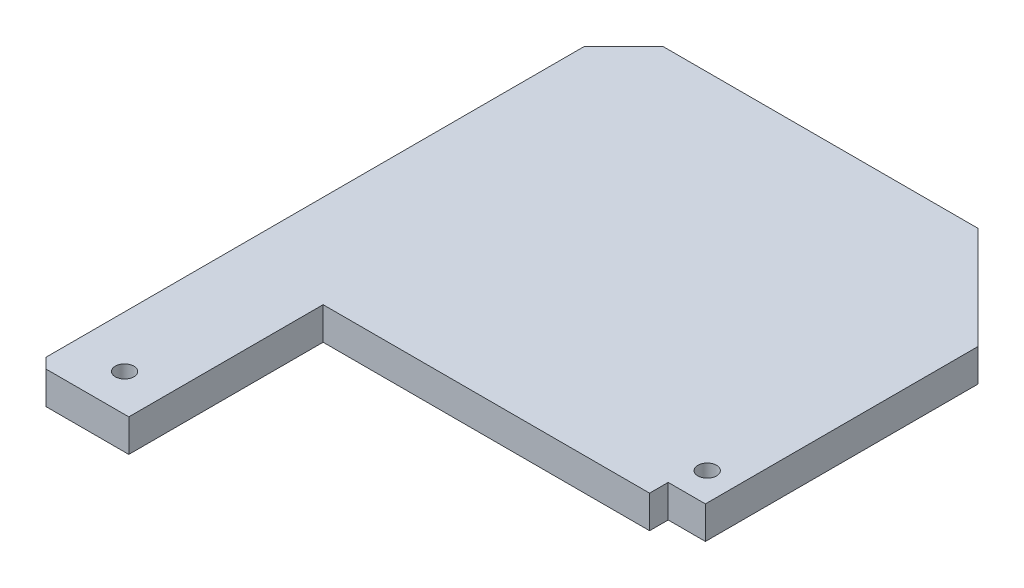
from build123d import *

# Parameters (mm, degrees)
SKETCH1_W                = 42.3
SKETCH1_H                = 42.3
BOSS_EXTRUDE1_DEPTH      = 3.5
CUT_EXTRUDE1_DEPTH       = 3.5
CIRPATTERN1_COUNT        = 4
SKETCH5_W                = 42.3
SKETCH5_H                = 3.5
BOSS_EXTRUDE3_DEPTH      = 6.79
BOSS_EXTRUDE3_DEPTH_BACK = 6.79
CUT_EXTRUDE2_REACH       = 5.5
SKETCH6_W                = 4
SKETCH6_H                = 2
BOSS_EXTRUDE4_DEPTH      = 3.5
CHAMFER1_SIZE            = 1.1
SKETCH8_R                = 1
CUT_EXTRUDE3_DEPTH       = 3.5
CHAMFER2_SIZE            = 11
SKETCH10_R               = 1
CUT_EXTRUDE4_DEPTH       = 3.5


with BuildPart() as part:
    # Sketch1 → Boss-Extrude1 (new body)
    with BuildSketch(Plane(origin=(0, 0, 0), x_dir=(1, 0, 0), z_dir=(0, 1, 0))):
        Rectangle(SKETCH1_W, SKETCH1_H)
    extrude(amount=BOSS_EXTRUDE1_DEPTH)

    # Sketch2 → Cut-Extrude1 (cut)
    with BuildSketch(Plane(origin=(0, 3.5, 0), x_dir=(1, 0, 0), z_dir=(0, 1, 0))):
        Polygon((-21.15, 16.907359313), (-16.907359313, 21.15), (-21.15, 21.15), align=None)
    cut_extrude1 = extrude(amount=-CUT_EXTRUDE1_DEPTH, mode=Mode.SUBTRACT)

    # CirPattern1: Cut-Extrude1 ×4 about axis
    cirpattern1_axis = Axis((0, 0, 0), (0, 1, 0))
    for i in range(1, CIRPATTERN1_COUNT):
        add(cut_extrude1.rotate(cirpattern1_axis, i * 360 / CIRPATTERN1_COUNT), mode=Mode.SUBTRACT)

    # Sketch5 → Boss-Extrude3 (add, two sides)
    with BuildSketch(Plane(origin=(21.15, 0, 0), x_dir=(0, 0, -1), z_dir=(1, 0, 0))) as boss_extrude3_sk:
        with Locations((0, 1.75)):
            Rectangle(SKETCH5_W, SKETCH5_H)
    extrude(amount=BOSS_EXTRUDE3_DEPTH)
    extrude(boss_extrude3_sk.sketch, amount=-BOSS_EXTRUDE3_DEPTH_BACK)

    # Sketch6 → Cut-Extrude2 (cut, up to next)
    with BuildSketch(Plane(origin=(0, 3.5, 0), x_dir=(1, 0, 0), z_dir=(0, 1, 0)), mode=Mode.PRIVATE) as cut_extrude2_sk1:
        with Locations((25.94, -20.15)):
            Rectangle(SKETCH6_W, SKETCH6_H)
    cut_extrude2_tool1 = extrude(cut_extrude2_sk1.sketch, amount=-CUT_EXTRUDE2_REACH, mode=Mode.PRIVATE) & part.part
    add(cut_extrude2_tool1.solids().sort_by_distance((25.94, 3.5, 20.15))[0], mode=Mode.SUBTRACT)

    # Sketch7 → Boss-Extrude4 (add)
    with BuildSketch(Plane(origin=(0, 3.5, 0), x_dir=(1, 0, 0), z_dir=(0, 1, 0))):
        Polygon((-21.15, -16.907359313), (-21.15, -42.036504825), (-11.15, -42.036504825), (-11.15, -21.15), (-16.907359313, -21.15), align=None)
    extrude(amount=-BOSS_EXTRUDE4_DEPTH)

    # Chamfer1
    chamfer1_edges = [part.edges().sort_by_distance(p)[0] for p in [
        (-21.15, 1.75, 42.036504825),
    ]]
    chamfer(chamfer1_edges, length=CHAMFER1_SIZE)

    # Sketch8 → Cut-Extrude3 (cut)
    with BuildSketch(Plane.XZ):
        with Locations((-15.6, 38.036504825)):
            Circle(SKETCH8_R)
    extrude(amount=-CUT_EXTRUDE3_DEPTH, mode=Mode.SUBTRACT)

    # Chamfer2
    chamfer2_edges = [part.edges().sort_by_distance(p)[0] for p in [
        (27.94, 1.75, -21.15),
    ]]
    chamfer(chamfer2_edges, length=CHAMFER2_SIZE)

    # Sketch10 → Cut-Extrude4 (cut)
    with BuildSketch(Plane.XZ):
        with Locations((24.94, 15.956504825)):
            Circle(SKETCH10_R)
    extrude(amount=-CUT_EXTRUDE4_DEPTH, mode=Mode.SUBTRACT)


solid = part.part
